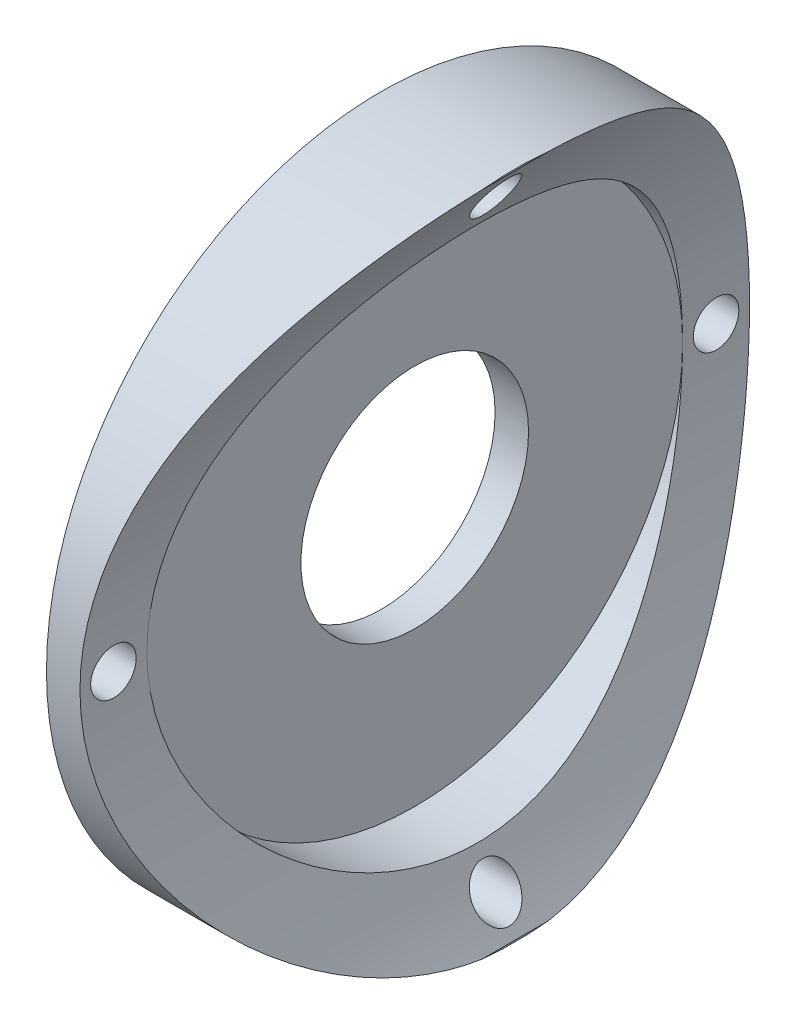
from build123d import *

# Parameters (mm, degrees)
SKETCH2_R                = 25
SKETCH2_R_2              = 8.5
BOSS_EXTRUDE1_DEPTH      = 10
SKETCH3_R                = 45
CUT_EXTRUDE3_DEPTH       = 29
CUT_EXTRUDE3_DEPTH_BACK  = 28
SKETCH5_R                = 20.000026056
CUT_EXTRUDE4_DEPTH       = 7.5
M3_CLEARANCE_HOLE1_D     = 3.4
M3_CLEARANCE_HOLE1_DEPTH = 70
M3_CLEARANCE_HOLE1_TIP   = 1.021463052


with BuildPart() as part:
    # Sketch2 → Boss-Extrude1 (new body)
    with BuildSketch(Plane(origin=(0, 0, 0), x_dir=(0, 0, -1), z_dir=(1, 0, 0))):
        Circle(SKETCH2_R)
        Circle(SKETCH2_R_2, mode=Mode.SUBTRACT)
    extrude(amount=BOSS_EXTRUDE1_DEPTH)

    # Sketch3 → Cut-Extrude3 (cut, two sides)
    with BuildSketch(Plane.XY) as cut_extrude3_sk:
        with Locations((47.5, 0)):
            Circle(SKETCH3_R)
    extrude(amount=CUT_EXTRUDE3_DEPTH, mode=Mode.SUBTRACT)
    extrude(cut_extrude3_sk.sketch, amount=-CUT_EXTRUDE3_DEPTH_BACK, mode=Mode.SUBTRACT)

    # Sketch5 → Cut-Extrude4 (cut)
    with BuildSketch(Plane(origin=(10, 0, 0), x_dir=(0, 0, -1), z_dir=(1, 0, 0))):
        Circle(SKETCH5_R)
    extrude(amount=-CUT_EXTRUDE4_DEPTH, mode=Mode.SUBTRACT)

    # M3 Clearance Hole1
    with Locations(Plane.ZY):
        with Locations((22.5, 0), (0, 22.5), (-22.5, 0), (0, -22.5)):
            Hole(M3_CLEARANCE_HOLE1_D / 2, depth=M3_CLEARANCE_HOLE1_DEPTH)
            with Locations((0, 0, -(M3_CLEARANCE_HOLE1_DEPTH + M3_CLEARANCE_HOLE1_TIP / 2))):  # 118° drill point
                Cone(0, M3_CLEARANCE_HOLE1_D / 2, M3_CLEARANCE_HOLE1_TIP, mode=Mode.SUBTRACT)


solid = part.part
